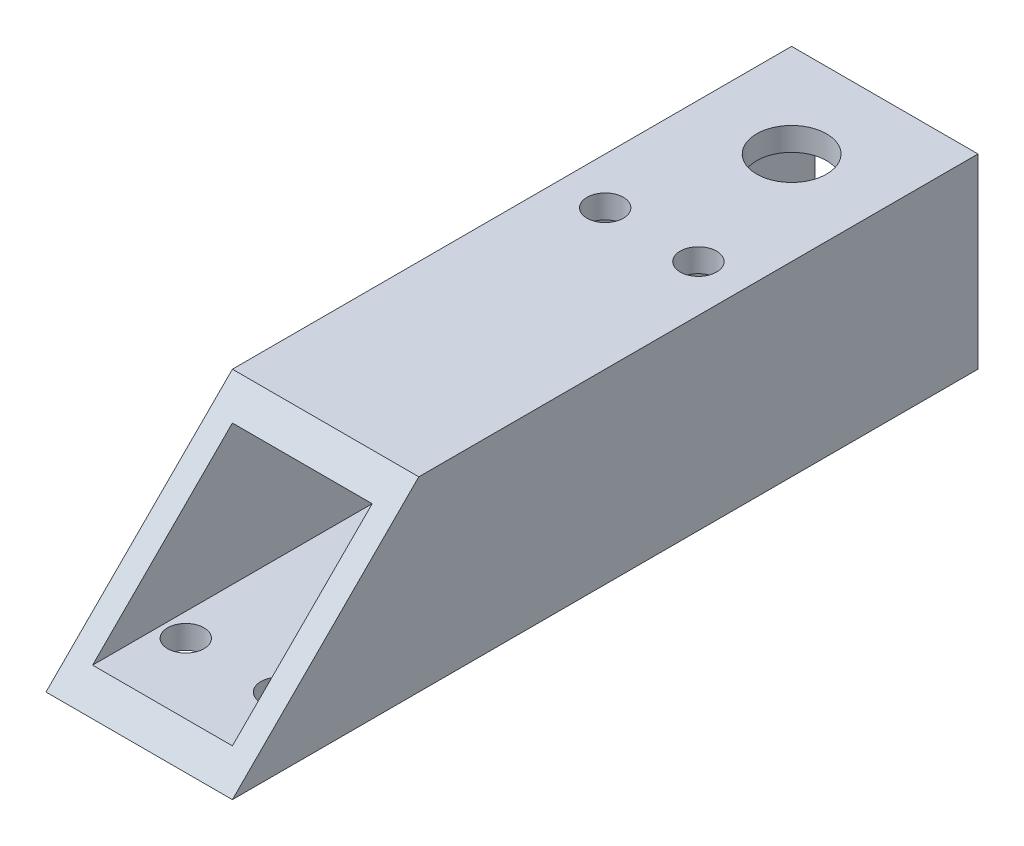
from build123d import *

# Parameters (mm, degrees)
SKETCH1_W           = 25.4
SKETCH1_H           = 25.4
BOSS_EXTRUDE1_DEPTH = 101.6
SKETCH2_W           = 19.05
SKETCH2_H           = 19.05
CUT_EXTRUDE1_DEPTH  = 102.6
CUT_EXTRUDE2_DEPTH  = 26.4
SKETCH5_R           = 2.4765
CUT_EXTRUDE3_DEPTH  = 26.4
SKETCH7_R           = 4.7625
CUT_EXTRUDE5_DEPTH  = 26.4
SKETCH8_R           = 2.4765
CUT_EXTRUDE6_DEPTH  = 26.4


with BuildPart() as part:
    # Sketch1 → Boss-Extrude1 (new body)
    with BuildSketch(Plane.XY):
        Rectangle(SKETCH1_W, SKETCH1_H)
    extrude(amount=BOSS_EXTRUDE1_DEPTH)

    # Sketch2 → Cut-Extrude1 (cut, through all)
    with BuildSketch(Plane.XY.offset(101.6)):
        Rectangle(SKETCH2_W, SKETCH2_H)
    extrude(amount=-CUT_EXTRUDE1_DEPTH, mode=Mode.SUBTRACT)

    # Sketch4 → Cut-Extrude2 (cut, through all)
    with BuildSketch(Plane(origin=(12.7, 0, 0), x_dir=(0, 0, -1), z_dir=(1, 0, 0))):
        Polygon((-101.6, 12.7), (-76.2, 12.7), (-101.6, -12.7), align=None)
    extrude(amount=-CUT_EXTRUDE2_DEPTH, mode=Mode.SUBTRACT)

    # Sketch5 → Cut-Extrude3 (cut, through all)
    with BuildSketch(Plane.XZ.offset(12.7)):
        with Locations((-6.35, 88.9)):
            Circle(SKETCH5_R)
        with Locations((6.35, 88.9)):
            Circle(SKETCH5_R)
    extrude(amount=-CUT_EXTRUDE3_DEPTH, mode=Mode.SUBTRACT)

    # Sketch7 → Cut-Extrude5 (cut, through all)
    with BuildSketch(Plane(origin=(0, 12.7, 0), x_dir=(1, 0, 0), z_dir=(0, 1, 0))):
        with Locations((0, -12.7)):
            Circle(SKETCH7_R)
    extrude(amount=-CUT_EXTRUDE5_DEPTH, mode=Mode.SUBTRACT)

    # Sketch8 → Cut-Extrude6 (cut, through all)
    with BuildSketch(Plane.XZ.offset(12.7)):
        with Locations((6.35, 31.75)):
            Circle(SKETCH8_R)
        with Locations((-6.35, 31.75)):
            Circle(SKETCH8_R)
    extrude(amount=-CUT_EXTRUDE6_DEPTH, mode=Mode.SUBTRACT)


solid = part.part
